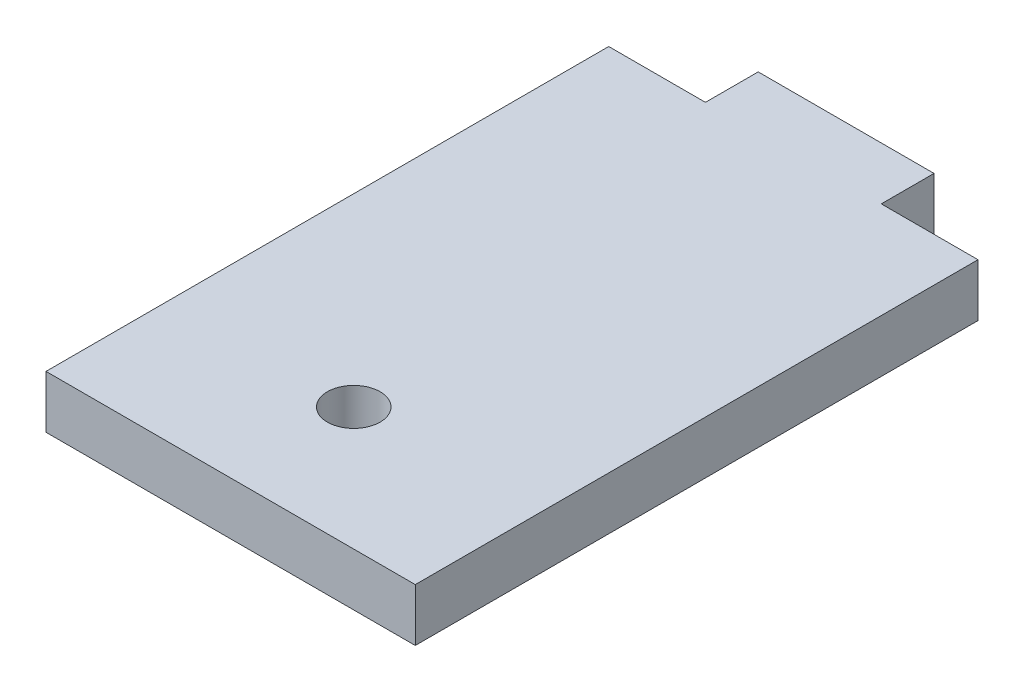
from build123d import *

# Parameters (mm, degrees)
CROQUIS1_R              = 1.5
SALIENTE_EXTRUIR1_DEPTH = 3


with BuildPart() as part:
    # Croquis1 → Saliente-Extruir1 (new body)
    with BuildSketch(Plane(origin=(0, 0, 0), x_dir=(1, 0, 0), z_dir=(0, 1, 0))):
        Polygon((0, 0), (10, 0), (10, -3), (15.5, -3), (15.5, -35), (-5.5, -35), (-5.5, -3), (0, -3), align=None)
        with Locations((5, -28)):
            Circle(CROQUIS1_R, mode=Mode.SUBTRACT)
    extrude(amount=SALIENTE_EXTRUIR1_DEPTH)


solid = part.part
